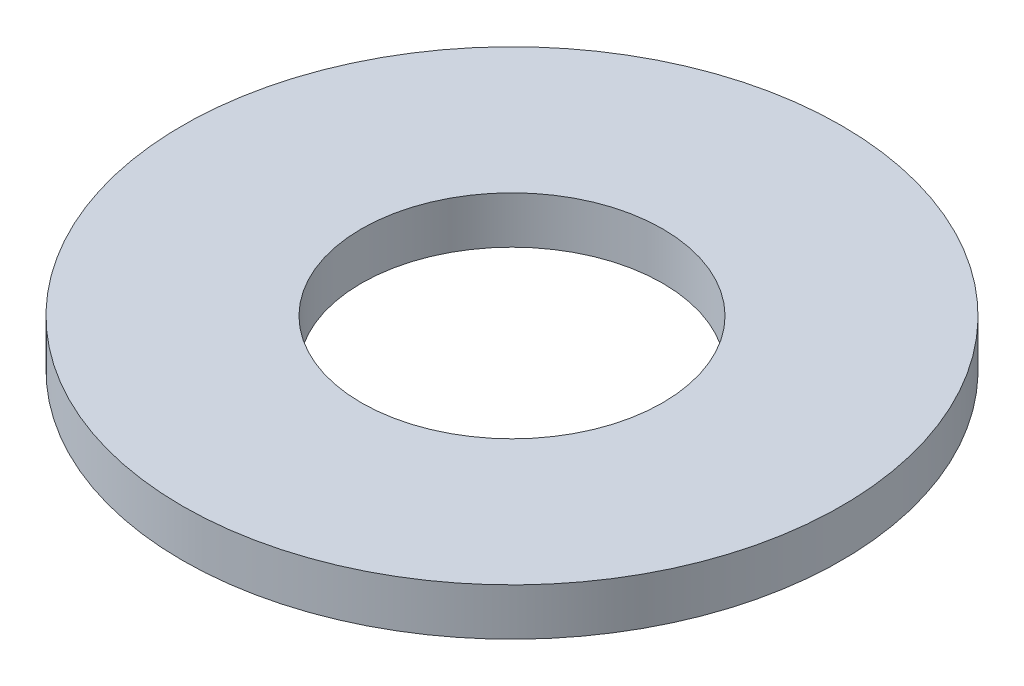
from build123d import *

# Parameters (mm, degrees)
SZKIC2_R                    = 3.5
SZKIC2_R_2                  = 1.6
DODANIE_WYCI_GNI_CIE1_DEPTH = 0.5


with BuildPart() as part:
    # Szkic2 → Dodanie-wyciągnięcie1 (new body)
    with BuildSketch(Plane(origin=(0, 0, 0), x_dir=(1, 0, 0), z_dir=(0, 1, 0))):
        Circle(SZKIC2_R)
        Circle(SZKIC2_R_2, mode=Mode.SUBTRACT)
    extrude(amount=DODANIE_WYCI_GNI_CIE1_DEPTH)


solid = part.part
